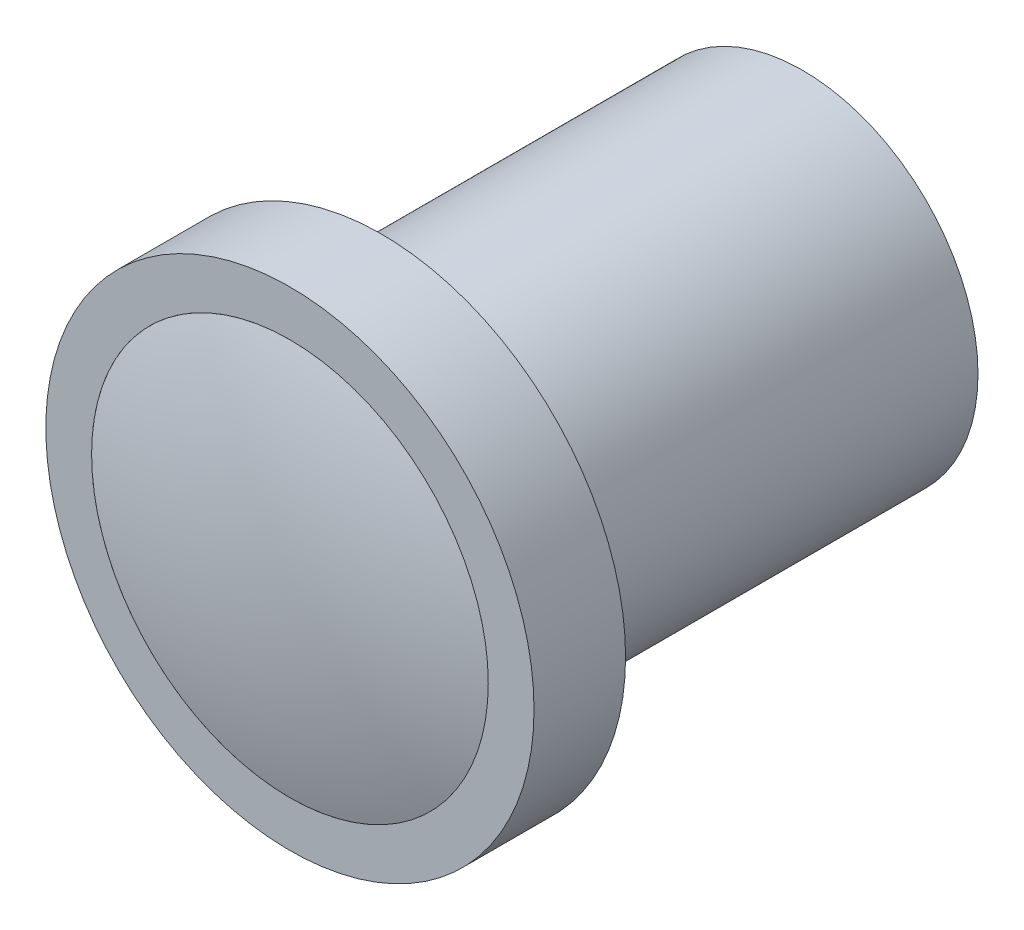
from build123d import *

# Parameters (mm, degrees)
SKETCH1_R           = 5.75
BOSS_EXTRUDE1_DEPTH = 13.8
SKETCH2_R           = 8
BOSS_EXTRUDE2_DEPTH = 3
SKETCH3_R           = 6.5
CUT_EXTRUDE1_DEPTH  = 2


with BuildPart() as part:
    # Sketch1 → Boss-Extrude1 (new body)
    with BuildSketch(Plane.XY):
        Circle(SKETCH1_R)
    extrude(amount=BOSS_EXTRUDE1_DEPTH)

    # Sketch2 → Boss-Extrude2 (add)
    with BuildSketch(Plane.XY.offset(13.8)):
        Circle(SKETCH2_R)
    extrude(amount=BOSS_EXTRUDE2_DEPTH)

    # Sketch3 → Cut-Extrude1 (cut)
    with BuildSketch(Plane.XY.offset(16.8)):
        Circle(SKETCH3_R)
    extrude(amount=-CUT_EXTRUDE1_DEPTH, mode=Mode.SUBTRACT)


with BuildPart() as body_2:
    # Sketch4 → Revolve1 (revolve)
    with BuildSketch(Plane(origin=(0, 0, 0), x_dir=(1, 0, 0), z_dir=(0, 1, 0))):
        with BuildLine():
            Line((0, -14.8), (0, -17.8))
            ThreePointArc((0, -17.8), (3.288236609, -17.548537962), (6.5, -16.8))
            Line((6.5, -16.8), (6.5, -14.8))
            Line((6.5, -14.8), (0, -14.8))
        make_face()
    revolve(axis=Axis((0, 0, 14.8), (0, 0, 1)))


solid = Compound([part.part, body_2.part])
